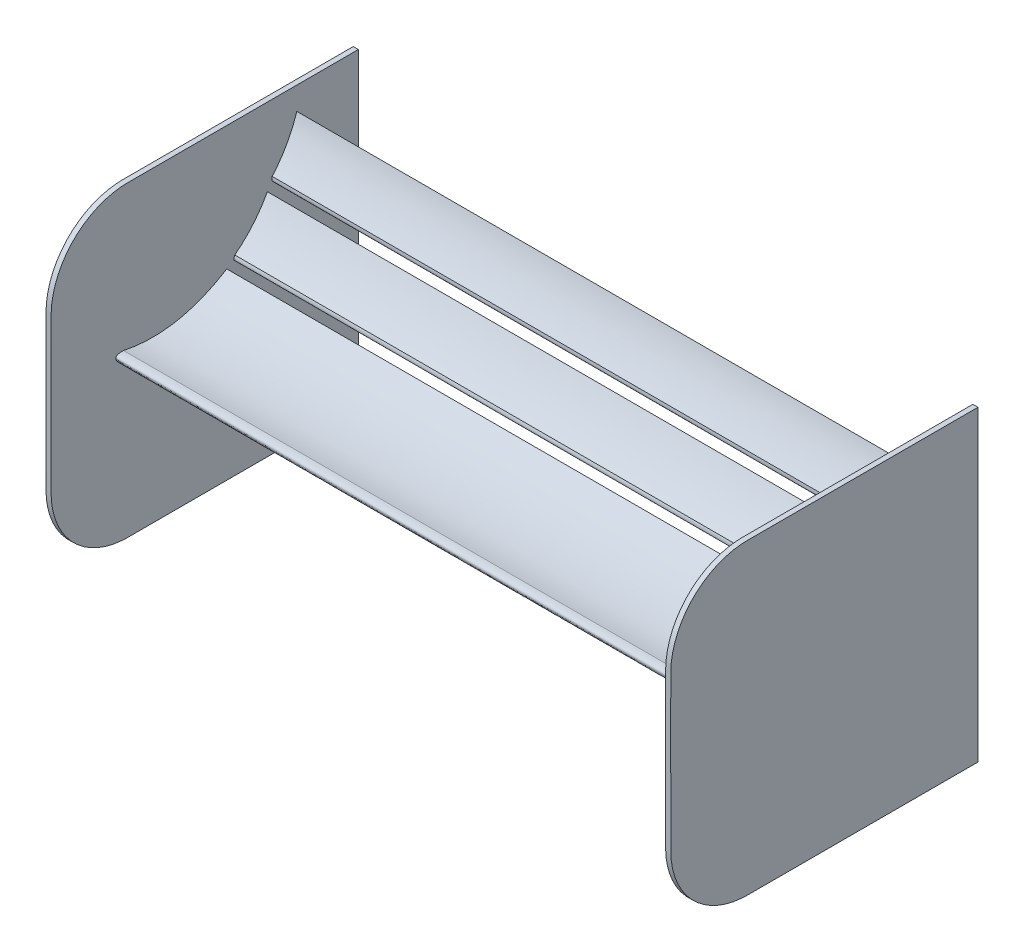
from build123d import *

# Parameters (mm, degrees)
THICKEN1_T1         = 1
BOSS_EXTRUDE1_DEPTH = 120


with BuildPart() as body_1:
    # Sketch1 → Surface-Fill1: a flat surface bounded by the sketch
    with BuildSketch(Plane(origin=(60, 0, 0), x_dir=(0, 0, -1), z_dir=(1, 0, 0)), mode=Mode.PRIVATE) as surface_fill1_1_region:
        with BuildLine():
            Line((41.73385696, -31.491181262), (-3.26614304, -31.491181262))
            ThreePointArc((-3.26614304, -31.491181262), (-13.872744757, -27.09778298), (-18.26614304, -16.491181262))
            Line((-18.26614304, -16.491181262), (-18.26614304, 13.508818738))
            ThreePointArc((-18.26614304, 13.508818738), (-13.872744757, 24.115420456), (-3.26614304, 28.508818738))
            Line((-3.26614304, 28.508818738), (41.73385696, 28.508818738))
            Line((41.73385696, 28.508818738), (41.73385696, -31.491181262))
        make_face()
    surface_fill1_1 = surface_fill1_1_region.sketch.faces()[0]
    add(Solid.thicken(surface_fill1_1, THICKEN1_T1))


with BuildPart() as body_2:
    # Mirror2: mirrored copy
    add(body_1.part.mirror(Plane(origin=(0, 0, 0), x_dir=(0, 0, 1), z_dir=(1, 0, 0))))


with BuildPart() as body_1_1:
    add(body_1.part)

    add(body_2.part)  # Boss-Extrude1 merges body 2
    # Sketch3 → Boss-Extrude1 (add)
    with BuildSketch(Plane(origin=(-60, 0, 0), x_dir=(0, 0, -1), z_dir=(1, 0, 0))):
        with BuildLine():
            add(Edge.make_bspline(
                [(-4.13171308, 0.53320251), (6.49703466, -1.725404901), (16.029496729, 4.251458417)],
                knots=[0, 0, 0, 1, 1, 1], degree=2))
            add(Edge.make_bspline(
                [(-4.13171308, 0.53320251), (-6.850100577, 0.626048916), (-4.598826839, -1.788632793), (-1.814150648, -3.025597835), (5.970634053, -3.23914719), (12.768670531, -0.720965872), (16.029496729, 4.251458417)],
                knots=[0, 0, 0, 0, 0.155837941, 0.221342977, 0.368312934, 1, 1, 1, 1], degree=3))
        make_face()
        with BuildLine():
            add(Edge.make_bspline(
                [(17.599427001, 5.821388689), (21.580097441, 8.903180986), (23.961775998, 13.340528413)],
                knots=[0, 0, 0, 1, 1, 1], degree=2))
            add(Edge.make_bspline(
                [(17.599427001, 5.821388689), (16.936117905, 4.353184636), (20.367936476, 5.555121016), (22.294567048, 8.514722554), (23.848210384, 11.561439664), (23.961775998, 13.340528413)],
                knots=[0, 0, 0, 0, 0.22856074, 0.553091354, 1, 1, 1, 1], degree=3))
        make_face()
        with BuildLine():
            add(Edge.make_bspline(
                [(24.900080531, 15.464591244), (28.219581151, 19.249310064), (29.71081576, 24.059576614)],
                knots=[0, 0, 0, 1, 1, 1], degree=2))
            add(Edge.make_bspline(
                [(24.900080531, 15.464591244), (24.529104832, 13.896796892), (27.668530956, 15.731472169), (28.995045302, 19.004315935), (29.938802804, 22.291505395), (29.71081576, 24.059576614)],
                knots=[0, 0, 0, 0, 0.22856074, 0.553091354, 1, 1, 1, 1], degree=3))
        make_face()
    extrude(amount=BOSS_EXTRUDE1_DEPTH)


solid = body_1_1.part
